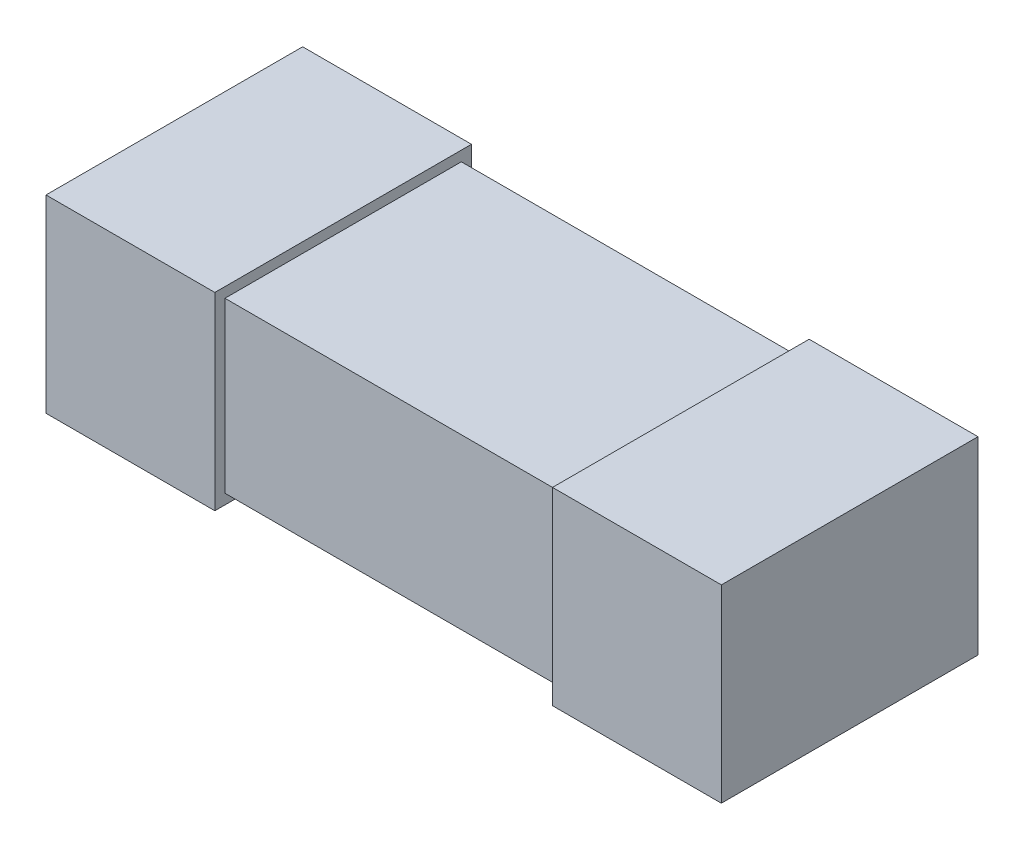
from build123d import *

# Parameters (mm, degrees)
SKETCH1_W           = 2
SKETCH1_H           = 0.7
BOSS_EXTRUDE1_DEPTH = 0.5
SKETCH2_W           = 0.76
SKETCH2_H           = 0.56
BOSS_EXTRUDE2_DEPTH = 0.5


with BuildPart() as part:
    # Sketch1 → Boss-Extrude1 (new body)
    with BuildSketch(Plane(origin=(0, 0, 0), x_dir=(1, 0, 0), z_dir=(0, 1, 0))):
        Rectangle(SKETCH1_W, SKETCH1_H)
    extrude(amount=BOSS_EXTRUDE1_DEPTH)

    # Sketch2 → Boss-Extrude2 (add)
    with BuildSketch(Plane.ZY.offset(1)):
        with Locations((0, 0.25)):
            Rectangle(SKETCH2_W, SKETCH2_H)
    boss_extrude2 = extrude(amount=-BOSS_EXTRUDE2_DEPTH)

    # Mirror1: Boss-Extrude2 across plane
    add(boss_extrude2.mirror(Plane(origin=(0, 0, 0), x_dir=(0, 0, 1), z_dir=(1, 0, 0))))


solid = part.part
